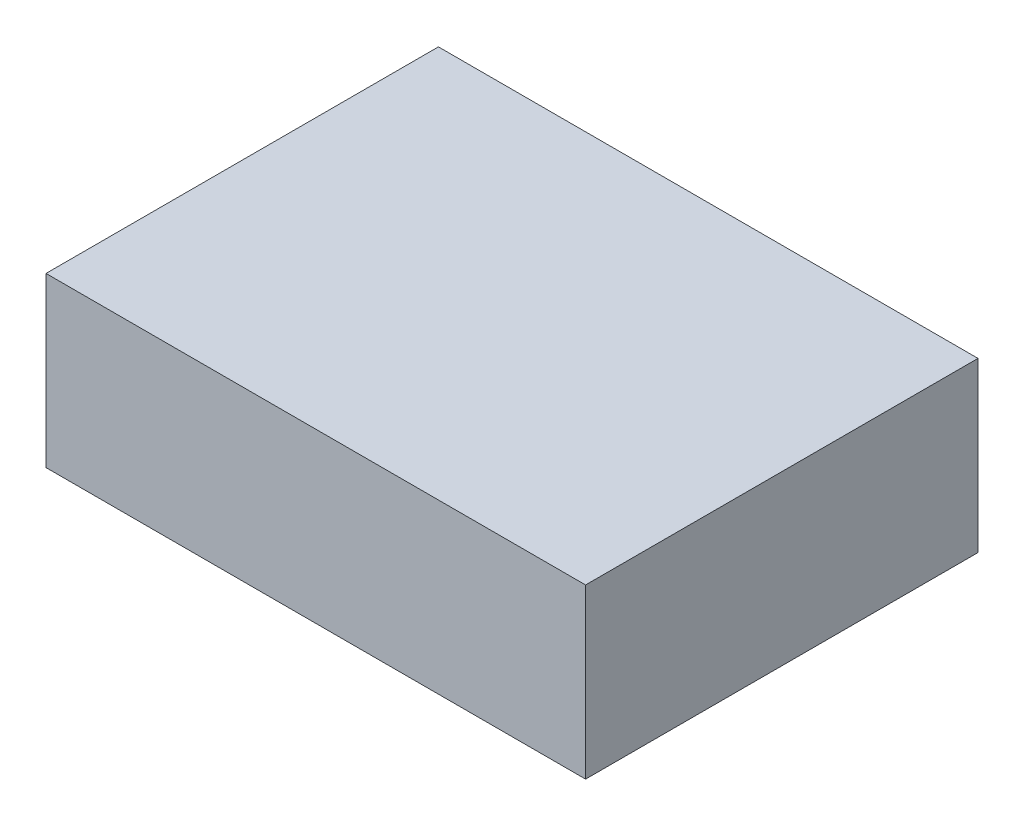
from build123d import *

# Parameters (mm, degrees)
SKETCH1_W           = 122.2375
SKETCH1_H           = 88.9
BOSS_EXTRUDE1_DEPTH = 38.1


with BuildPart() as part:
    # Sketch1 → Boss-Extrude1 (new body)
    with BuildSketch(Plane(origin=(0, 0, 0), x_dir=(1, 0, 0), z_dir=(0, 1, 0))):
        with Locations((61.11875, 44.45)):
            Rectangle(SKETCH1_W, SKETCH1_H)
    extrude(amount=BOSS_EXTRUDE1_DEPTH)


solid = part.part
